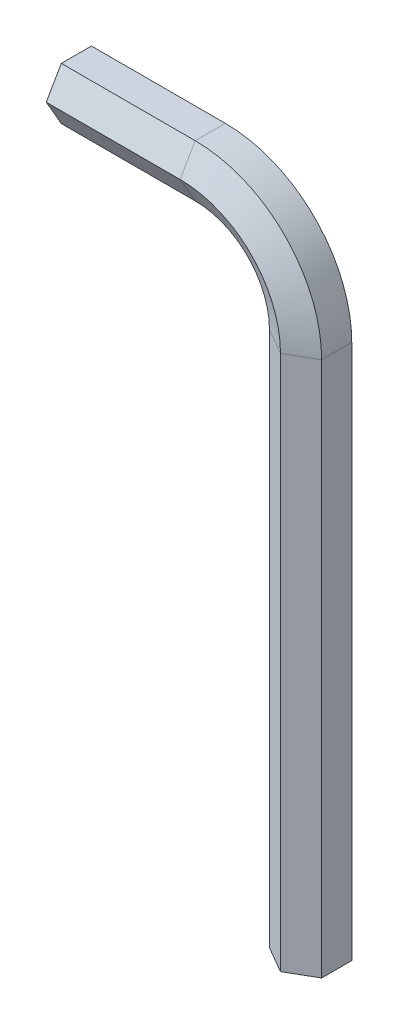
from build123d import *


with BuildPart() as part:
    # Sweep1: sweep along a path in Sketch1
    with BuildLine(Plane.XY) as sweep1_path:
        Line((0, 0), (0, 80))
        ThreePointArc((0, 80), (-4.393398282, 90.606601718), (-15, 95))
        Line((-15, 95), (-35, 95))
    # Sketch2 → Sweep1 (sweep)
    with BuildSketch(Plane(origin=(-35, 95, 0), x_dir=(0, 0, 1), z_dir=(-1, 0, 0))):
        Polygon((4.5, 0), (2.25, 3.897114317), (-2.25, 3.897114317), (-4.5, 0), (-2.25, -3.897114317), (2.25, -3.897114317), align=None)
    sweep(path=sweep1_path.line)


solid = part.part
